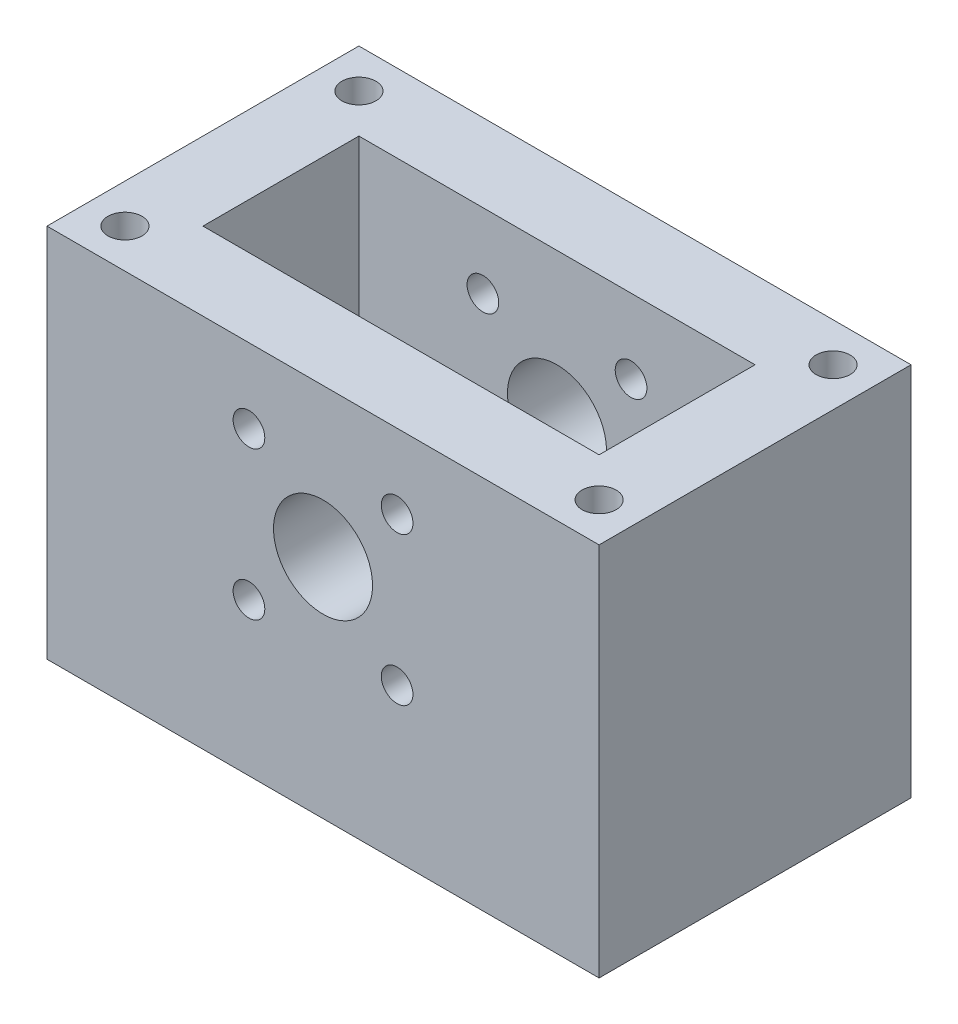
from build123d import *

# Parameters (mm, degrees)
SKETCH1_W           = 25.4
SKETCH1_H           = 19.05
SKETCH1_R           = 3.175
SKETCH1_R_2         = 1.016
BOSS_EXTRUDE1_DEPTH = 5
SKETCH1_3_W         = 25.4
SKETCH1_3_H         = 5
BOSS_EXTRUDE2_DEPTH = 20
BOSS_EXTRUDE3_START = 20
SKETCH1_4_W         = 25.4
SKETCH1_4_H         = 19.05
SKETCH1_4_R         = 3.175
SKETCH1_4_R_2       = 1.016
BOSS_EXTRUDE3_DEPTH = 5
SKETCH2_R           = 1.0922
CUT_EXTRUDE1_DEPTH  = 10


with BuildPart() as part:
    # Sketch1 → Boss-Extrude1 (new body)
    with BuildSketch(Plane.XY):
        with Locations((12.7, -9.525)):
            Rectangle(SKETCH1_W, SKETCH1_H)
        with Locations((12.7, -9.525)):
            Circle(SKETCH1_R, mode=Mode.SUBTRACT)
        with Locations((17.4498, -14.2748)):
            Circle(SKETCH1_R_2, mode=Mode.SUBTRACT)
        with Locations((7.9502, -14.2748)):
            Circle(SKETCH1_R_2, mode=Mode.SUBTRACT)
        with Locations((17.4498, -4.7752)):
            Circle(SKETCH1_R_2, mode=Mode.SUBTRACT)
        with Locations((7.9502, -4.7752)):
            Circle(SKETCH1_R_2, mode=Mode.SUBTRACT)
    extrude(amount=BOSS_EXTRUDE1_DEPTH)

    # Sketch1_3 → Boss-Extrude2 (add)
    with BuildSketch(Plane.XY):
        with Locations((12.7, -21.55)):
            Rectangle(SKETCH1_3_W, SKETCH1_3_H)
        Polygon((30.4, 0), (30.4, -24.05), (25.4, -24.05), (25.4, -19.05), (25.4, 0), align=None)
        Polygon((-5, 0), (-5, -24.05), (0, -24.05), (0, -19.05), (0, 0), align=None)
    extrude(amount=BOSS_EXTRUDE2_DEPTH)

    # Sketch1_4 → Boss-Extrude3 (add)
    with BuildSketch(Plane.XY.offset(BOSS_EXTRUDE3_START)):
        with Locations((12.7, -9.525)):
            Rectangle(SKETCH1_4_W, SKETCH1_4_H)
        with Locations((12.7, -9.525)):
            Circle(SKETCH1_4_R, mode=Mode.SUBTRACT)
        with Locations((17.4498, -14.2748)):
            Circle(SKETCH1_4_R_2, mode=Mode.SUBTRACT)
        with Locations((7.9502, -14.2748)):
            Circle(SKETCH1_4_R_2, mode=Mode.SUBTRACT)
        with Locations((17.4498, -4.7752)):
            Circle(SKETCH1_4_R_2, mode=Mode.SUBTRACT)
        with Locations((7.9502, -4.7752)):
            Circle(SKETCH1_4_R_2, mode=Mode.SUBTRACT)
    extrude(amount=-BOSS_EXTRUDE3_DEPTH)

    # Sketch2 → Cut-Extrude1 (cut)
    with BuildSketch(Plane(origin=(0, 0, 0), x_dir=(1, 0, 0), z_dir=(0, 1, 0))):
        with Locations((-2.5, -2.5)):
            Circle(SKETCH2_R)
        with Locations((27.9, -2.5)):
            Circle(SKETCH2_R)
        with Locations((27.9, -17.5)):
            Circle(SKETCH2_R)
        with Locations((-2.5, -17.5)):
            Circle(SKETCH2_R)
    extrude(amount=-CUT_EXTRUDE1_DEPTH, mode=Mode.SUBTRACT)


solid = part.part
